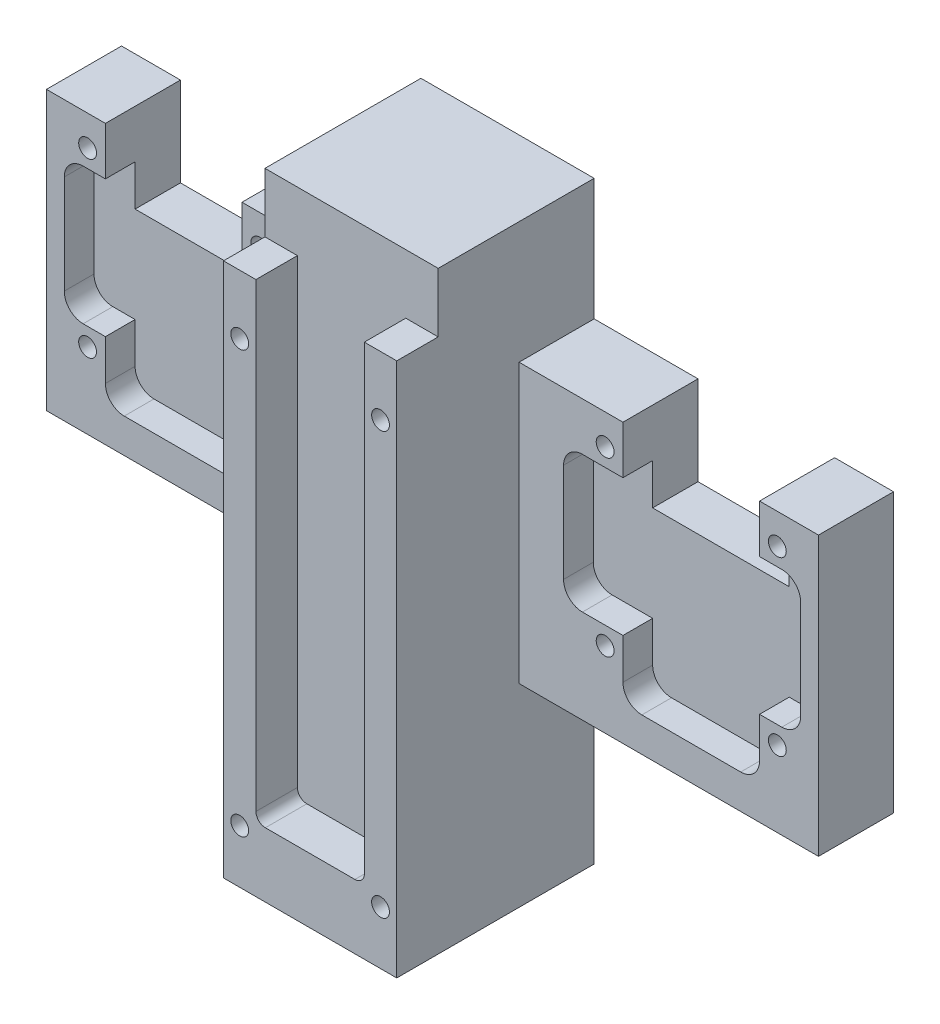
from build123d import *

# Parameters (mm, degrees)
SKETCH1_W           = 130
SKETCH1_H           = 104.86
BOSS_EXTRUDE1_DEPTH = 39.84
SKETCH2_W           = 130
SKETCH2_H           = 94.86
CUT_EXTRUDE1_DEPTH  = 6.6
SKETCH3_W           = 18.25
SKETCH3_H           = 89.15
CUT_EXTRUDE2_DEPTH  = 6.98
SKETCH5_W           = 50.415
SKETCH5_H           = 94.86
CUT_EXTRUDE3_DEPTH  = 20.6
SKETCH6_R           = 1.5
CUT_EXTRUDE4_DEPTH  = 12.4
SKETCH7_W           = 50.415
SKETCH7_H           = 20.5
CUT_EXTRUDE5_DEPTH  = 12.4
SKETCH9_W           = 23
SKETCH9_H           = 15
CUT_EXTRUDE7_DEPTH  = 12.4
CUT_EXTRUDE8_DEPTH  = 5
SKETCH11_R          = 1.5
CUT_EXTRUDE9_DEPTH  = 15
FILLET2_R           = 3.175
FILLET3_R           = 3.175
FILLET4_R           = 3.175
FILLET5_R           = 1.5875
FILLET6_R           = 3.175
SKETCH12_W          = 50.415
SKETCH12_H          = 20.5
SKETCH12_W_2        = 23
SKETCH12_H_2        = 15
SKETCH12_H_3        = 27.5
SKETCH12_W_3        = 29.17
SKETCH12_H_4        = 4.86
CUT_EXTRUDE11_DEPTH = 42
SKETCH13_W          = 6.6
SKETCH13_H          = 5.14
CUT_EXTRUDE12_DEPTH = 80.585
SKETCH14_W          = 29.17
SKETCH14_H          = 10
CUT_EXTRUDE14_DEPTH = 6.98
CUT_EXTRUDE15_DEPTH = 9


with BuildPart() as part:
    # Sketch1 → Boss-Extrude1 (new body)
    with BuildSketch(Plane.XY):
        with Locations((65, -52.43)):
            Rectangle(SKETCH1_W, SKETCH1_H)
    extrude(amount=BOSS_EXTRUDE1_DEPTH)

    # Sketch2 → Cut-Extrude1 (cut)
    with BuildSketch(Plane.XY.offset(39.84)):
        with Locations((65, -47.43)):
            Rectangle(SKETCH2_W, SKETCH2_H)
    extrude(amount=-CUT_EXTRUDE1_DEPTH, mode=Mode.SUBTRACT)

    # Sketch3 → Cut-Extrude2 (cut)
    with BuildSketch(Plane.XY.offset(33.24)):
        with Locations((65, -44.575)):
            Rectangle(SKETCH3_W, SKETCH3_H)
    extrude(amount=-CUT_EXTRUDE2_DEPTH, mode=Mode.SUBTRACT)

    # Sketch5 → Cut-Extrude3 (cut)
    with BuildSketch(Plane.XY.offset(33.24)):
        with Locations((104.7925, -47.43)):
            Rectangle(SKETCH5_W, SKETCH5_H)
        with Locations((25.2075, -47.43)):
            Rectangle(SKETCH5_W, SKETCH5_H)
    extrude(amount=-CUT_EXTRUDE3_DEPTH, mode=Mode.SUBTRACT)

    # Sketch6 → Cut-Extrude4 (cut)
    with BuildSketch(Plane.XY.offset(12.64)):
        with Locations((35.925, -25.6)):
            Circle(SKETCH6_R)
        with Locations((6.925, -25.6)):
            Circle(SKETCH6_R)
        with Locations((35.925, -54.6)):
            Circle(SKETCH6_R)
        with Locations((6.925, -54.6)):
            Circle(SKETCH6_R)
        with Locations((94.075, -25.6)):
            Circle(SKETCH6_R)
        with Locations((123.075, -25.6)):
            Circle(SKETCH6_R)
        with Locations((94.075, -54.6)):
            Circle(SKETCH6_R)
        with Locations((123.075, -54.6)):
            Circle(SKETCH6_R)
    extrude(amount=-CUT_EXTRUDE4_DEPTH, mode=Mode.SUBTRACT)

    # Sketch7 → Cut-Extrude5 (cut)
    with BuildSketch(Plane.XY.offset(12.64)):
        with Locations((25.2075, -10.25)):
            Rectangle(SKETCH7_W, SKETCH7_H)
        with Locations((104.7925, -10.25)):
            Rectangle(SKETCH7_W, SKETCH7_H)
    extrude(amount=-CUT_EXTRUDE5_DEPTH, mode=Mode.SUBTRACT)

    # Sketch9 → Cut-Extrude7 (cut)
    with BuildSketch(Plane.XY.offset(12.64)):
        with Locations((108.575, -28)):
            Rectangle(SKETCH9_W, SKETCH9_H)
        with Locations((21.425, -28)):
            Rectangle(SKETCH9_W, SKETCH9_H)
    extrude(amount=-CUT_EXTRUDE7_DEPTH, mode=Mode.SUBTRACT)

    # Sketch10 → Cut-Extrude8 (cut)
    with BuildSketch(Plane.XY.offset(12.64)):
        Polygon((9.925, -28.6), (3, -28.6), (3, -51.6), (9.925, -51.6), (9.925, -61.6), (32.925, -61.6), (32.925, -51.6), (42.925, -51.6), (42.925, -28.6), (32.925, -28.6), (32.925, -35.5), (9.925, -35.5), align=None)
        Polygon((97.075, -28.6), (87.075, -28.6), (87.075, -51.6), (97.075, -51.6), (97.075, -61.6), (120.075, -61.6), (120.075, -51.6), (127, -51.6), (127, -28.6), (120.075, -28.6), (120.075, -35.5), (97.075, -35.5), align=None)
    extrude(amount=-CUT_EXTRUDE8_DEPTH, mode=Mode.SUBTRACT)

    # Sketch11 → Cut-Extrude9 (cut)
    with BuildSketch(Plane.XY.offset(33.24)):
        with Locations((53.145, -20)):
            Circle(SKETCH11_R)
        with Locations((76.855, -20)):
            Circle(SKETCH11_R)
        with Locations((53.145, -91)):
            Circle(SKETCH11_R)
        with Locations((76.855, -91)):
            Circle(SKETCH11_R)
    extrude(amount=-CUT_EXTRUDE9_DEPTH, mode=Mode.SUBTRACT)

    # Fillet2
    fillet2_edges = [part.edges().sort_by_distance(p)[0] for p in [
        (3, -51.6, 10.14),
    ]]
    fillet(fillet2_edges, radius=FILLET2_R)

    # Fillet3
    fillet3_edges = [part.edges().sort_by_distance(p)[0] for p in [
        (50.415, -20.5, 6.44),
        (79.585, -20.5, 6.44),
        (32.925, -35.5, 3.94),
        (9.925, -35.5, 3.94),
        (42.925, -28.6, 10.14),
        (42.925, -51.6, 10.14),
        (32.925, -61.6, 10.14),
        (9.925, -61.6, 10.14),
        (3, -28.6, 10.14),
        (127, -28.6, 10.14),
        (127, -51.6, 10.14),
        (120.075, -61.6, 10.14),
        (97.075, -61.6, 10.14),
        (87.075, -51.6, 10.14),
        (87.075, -28.6, 10.14),
    ]]
    fillet(fillet3_edges, radius=FILLET3_R)

    # Fillet4
    fillet4_edges = [part.edges().sort_by_distance(p)[0] for p in [
        (120.075, -35.5, 3.94),
        (97.075, -35.5, 3.94),
    ]]
    fillet(fillet4_edges, radius=FILLET4_R)

    # Fillet5
    fillet5_edges = [part.edges().sort_by_distance(p)[0] for p in [
        (74.125, -89.15, 29.75),
        (55.875, -89.15, 29.75),
    ]]
    fillet(fillet5_edges, radius=FILLET5_R)

    # Fillet6
    fillet6_edges = [part.edges().sort_by_distance(p)[0] for p in [
        (79.585, -94.86, 22.94),
        (50.415, -94.86, 22.94),
    ]]
    fillet(fillet6_edges, radius=FILLET6_R)

    # Sketch12 → Cut-Extrude11 (cut)
    with BuildSketch(Plane.XY.offset(39.84)):
        with Locations((25.2075, -10.25)):
            Rectangle(SKETCH12_W, SKETCH12_H)
        with Locations((104.7925, -10.25)):
            Rectangle(SKETCH12_W, SKETCH12_H)
        with Locations((108.575, -28)):
            Rectangle(SKETCH12_W_2, SKETCH12_H_2)
        with Locations((21.425, -28)):
            Rectangle(SKETCH12_W_2, SKETCH12_H_2)
        with Locations((25.2075, -81.11)):
            Rectangle(SKETCH12_W, SKETCH12_H_3)
        with Locations((104.7925, -81.11)):
            Rectangle(SKETCH12_W, SKETCH12_H_3)
        Polygon((130, -94.86), (79.585, -94.86), (79.585, -100), (79.585, -104.86), (130, -104.86), align=None)
        Polygon((50.415, -94.86), (0, -94.86), (0, -104.86), (50.415, -104.86), (50.415, -100), (50.415, -95.14), align=None)
        with Locations((65, -102.43)):
            Rectangle(SKETCH12_W_3, SKETCH12_H_4)
    extrude(amount=-CUT_EXTRUDE11_DEPTH, mode=Mode.SUBTRACT)

    # Sketch13 → Cut-Extrude12 (cut, through all)
    with BuildSketch(Plane(origin=(79.585, 0, 0), x_dir=(0, 0, -1), z_dir=(1, 0, 0))):
        with Locations((-36.54, -97.43)):
            Rectangle(SKETCH13_W, SKETCH13_H)
    extrude(amount=-CUT_EXTRUDE12_DEPTH, mode=Mode.SUBTRACT)

    # Sketch14 → Cut-Extrude14 (cut)
    with BuildSketch(Plane.XY.offset(33.24)):
        with Locations((65, -5)):
            Rectangle(SKETCH14_W, SKETCH14_H)
    extrude(amount=-CUT_EXTRUDE14_DEPTH, mode=Mode.SUBTRACT)

    # Sketch15 → Cut-Extrude15 (cut)
    with BuildSketch(Plane(origin=(0, 0, 0), x_dir=(-1, 0, 0), z_dir=(0, 0, -1))):
        with BuildLine():
            Line((-73.585, -100), (-56.415, -100))
            Line((-56.415, -100), (-56.415, -23.5))
            ThreePointArc((-56.415, -23.5), (-57.440126266, -21.025126266), (-59.915, -20))
            Line((-59.915, -20), (-70.085, -20))
            ThreePointArc((-70.085, -20), (-72.559873734, -21.025126266), (-73.585, -23.5))
            Line((-73.585, -23.5), (-73.585, -100))
        make_face()
    extrude(amount=-CUT_EXTRUDE15_DEPTH, mode=Mode.SUBTRACT)


solid = part.part
